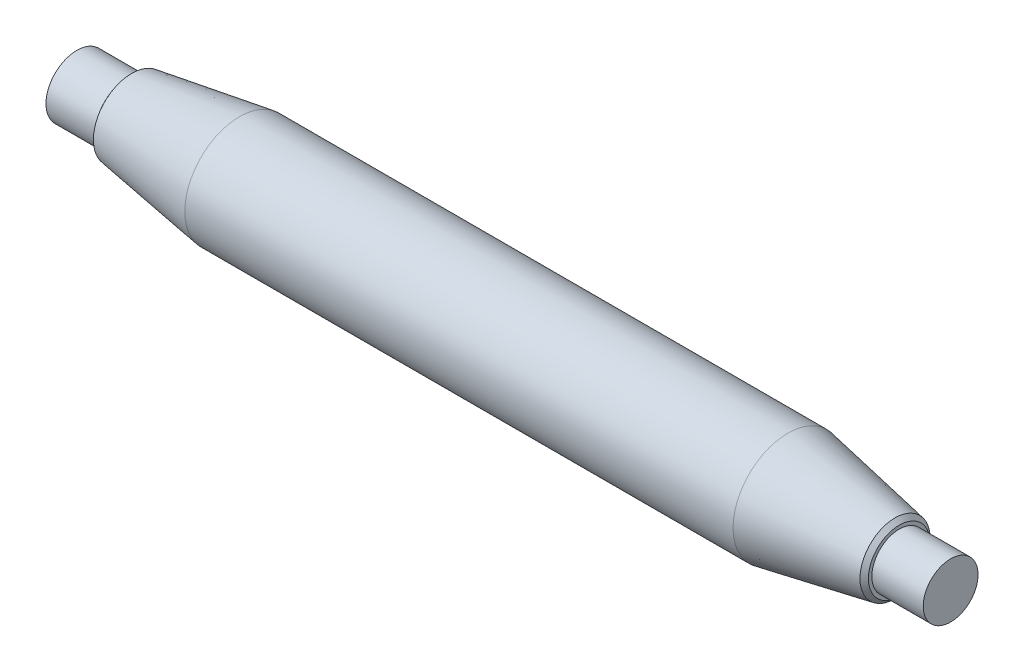
from build123d import *

# Parameters (mm, degrees)
CHANFREIN1_SIZE              = 1.195722403
CHANFREIN1_SIZE2             = 1
CHANFREIN1_EDGE_2_SIZE       = 1.247139839
CHANFREIN1_EDGE_2_SIZE2      = 1
ENL_V_MAT_EXTRU_1_DEPTH      = 17
ENL_V_MAT_EXTRU_1_DEPTH_BACK = 17


with BuildPart() as part:
    # Esquisse1 → Révolution1 (revolve)
    with BuildSketch(Plane.XY, mode=Mode.PRIVATE) as r_volution1_sk:
        Polygon((-127.5, 0), (-127.5, 9), (-112.5, 9), (-112.5, 11), (-80, 16), (80, 16), (112.5, 10), (112.5, 8), (127.5, 8), (127.5, 0), align=None)
    revolve(r_volution1_sk.sketch.rotate(Axis((-127.5, 0, 0), (1, 0, 0)), 90), axis=Axis((-127.5, 0, 0), (1, 0, 0)))  # turned: the seam where the file's is

    # Chanfrein1
    chanfrein1_edges = [part.edges().sort_by_distance(p)[0] for p in [
        (-112.5, 0, -11),
    ]]
    chanfrein1_side = [part.faces().sort_by_distance(p)[0] for p in [
        (-112.5, 0, -9.311126984),
    ]]
    chamfer(chanfrein1_edges, length=CHANFREIN1_SIZE, length2=CHANFREIN1_SIZE2, reference=chanfrein1_side[0])

    # Chanfrein1 edge 2
    chanfrein1_edge_2_edges = [part.edges().sort_by_distance(p)[0] for p in [
        (112.5, 0, -10),
    ]]
    chanfrein1_edge_2_side = [part.faces().sort_by_distance(p)[0] for p in [
        (96.25, 0, -13),
    ]]
    chamfer(chanfrein1_edge_2_edges, length=CHANFREIN1_EDGE_2_SIZE, length2=CHANFREIN1_EDGE_2_SIZE2, reference=chanfrein1_edge_2_side[0])

    # Esquisse2 → Enlèv. mat.-Extru.1 (cut, two sides)
    with BuildSketch(Plane(origin=(0, 0, 0), x_dir=(1, 0, 0), z_dir=(0, 1, 0))) as enl_v_mat_extru_1_sk:
        Polygon((-25, 16), (-24.322079679, 11.176346273), (10, 16), align=None)
    extrude(amount=ENL_V_MAT_EXTRU_1_DEPTH, mode=Mode.SUBTRACT)
    extrude(enl_v_mat_extru_1_sk.sketch, amount=-ENL_V_MAT_EXTRU_1_DEPTH_BACK, mode=Mode.SUBTRACT)


solid = part.part
